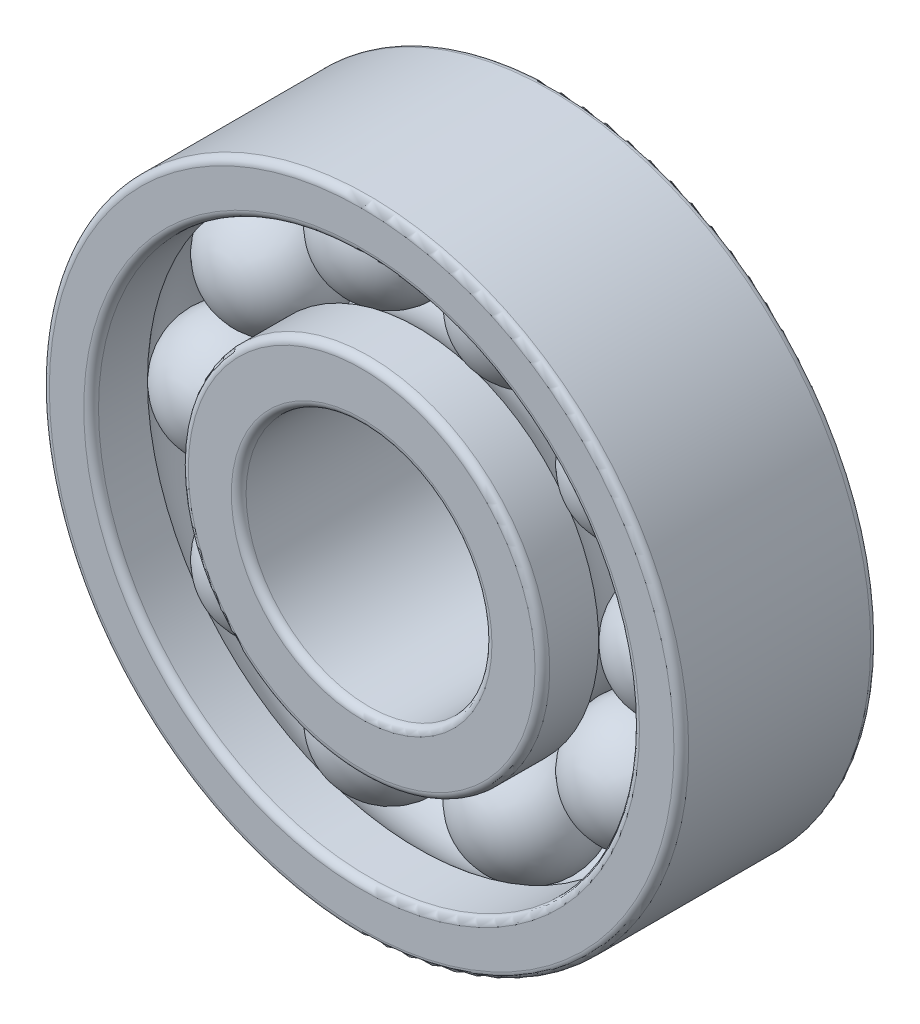
from build123d import *

# Parameters (mm, degrees)
SKETCH1_R             = 13
SKETCH1_R_2           = 11
BOSS_EXTRUDE1_DEPTH   = 8
SKETCH1_R_3           = 7.35
SKETCH1_R_4           = 5
BOSS_EXTRUDE1_2_DEPTH = 8
SKETCH4_R             = 2.5
CIRPATTERN1_COUNT     = 10
FILLET1_R             = 0.3
FILLET2_R             = 0.3


with BuildPart() as part:
    # Sketch1 → Boss-Extrude1 (new body)
    with BuildSketch(Plane.XY):
        Circle(SKETCH1_R)
        Circle(SKETCH1_R_2, mode=Mode.SUBTRACT)
    extrude(amount=BOSS_EXTRUDE1_DEPTH)


with BuildPart() as body_2:
    # Sketch1 → Boss-Extrude1 2 (new body)
    with BuildSketch(Plane.XY):
        Circle(SKETCH1_R_3)
        Circle(SKETCH1_R_4, mode=Mode.SUBTRACT)
    extrude(amount=BOSS_EXTRUDE1_2_DEPTH)


with BuildPart() as cut_sweep1_tool:
    # Cut-Sweep1: sweep along a path in Sketch2
    with BuildLine(Plane.XY.offset(4)) as cut_sweep1_path:
        CenterArc((0, 0), 9.175, 0, 360)
    # Sketch4 → Cut-Sweep1 (sweep)
    with BuildSketch(Plane(origin=(0, 0, 0), x_dir=(1, 0, 0), z_dir=(0, 1, 0))):
        with Locations((-9.175, -4)):
            Circle(SKETCH4_R)
    sweep(path=cut_sweep1_path.line)


with BuildPart() as part_1:
    add(part.part)

    # Cut-Sweep1: cut by cut_sweep1_tool
    add(cut_sweep1_tool.part, mode=Mode.SUBTRACT)

    # Fillet1
    fillet1_edges = [part_1.edges().sort_by_distance(p)[0] for p in [
        (-11, 0, 0),
        (-13, 0, 0),
        (-11, 0, 8),
        (-13, 0, 8),
    ]]
    fillet(fillet1_edges, radius=FILLET1_R)


with BuildPart() as body_2_1:
    add(body_2.part)

    # Cut-Sweep1: cut by cut_sweep1_tool
    add(cut_sweep1_tool.part, mode=Mode.SUBTRACT)

    # Fillet2
    fillet2_edges = [body_2_1.edges().sort_by_distance(p)[0] for p in [
        (-5, 0, 8),
        (-7.35, 0, 8),
        (-5, 0, 0),
        (-7.35, 0, 0),
    ]]
    fillet(fillet2_edges, radius=FILLET2_R)


with BuildPart() as body_3:
    # Sketch5 → Revolve1 (revolve)
    with BuildSketch(Plane(origin=(0, 0, 0), x_dir=(1, 0, 0), z_dir=(0, 1, 0))):
        with BuildLine():
            Line((-9.175, -1.5), (-9.175, -6.5))
            ThreePointArc((-9.175, -6.5), (-11.675, -4), (-9.175, -1.5))
        make_face()
    revolve(axis=Axis((-9.175, 0, 1.5), (0, 0, 1)))


with BuildPart() as cirpattern1_1:
    # CirPattern1: pattern copy
    add(body_3.part.rotate(Axis((0, 0, 8), (0, 0, -1)), 1 * 360 / CIRPATTERN1_COUNT))


with BuildPart() as cirpattern1_2:
    # CirPattern1: pattern copy
    add(body_3.part.rotate(Axis((0, 0, 8), (0, 0, -1)), 2 * 360 / CIRPATTERN1_COUNT))


with BuildPart() as cirpattern1_3:
    # CirPattern1: pattern copy
    add(body_3.part.rotate(Axis((0, 0, 8), (0, 0, -1)), 3 * 360 / CIRPATTERN1_COUNT))


with BuildPart() as cirpattern1_4:
    # CirPattern1: pattern copy
    add(body_3.part.rotate(Axis((0, 0, 8), (0, 0, -1)), 4 * 360 / CIRPATTERN1_COUNT))


with BuildPart() as cirpattern1_5:
    # CirPattern1: pattern copy
    add(body_3.part.rotate(Axis((0, 0, 8), (0, 0, -1)), 5 * 360 / CIRPATTERN1_COUNT))


with BuildPart() as cirpattern1_6:
    # CirPattern1: pattern copy
    add(body_3.part.rotate(Axis((0, 0, 8), (0, 0, -1)), 6 * 360 / CIRPATTERN1_COUNT))


with BuildPart() as cirpattern1_7:
    # CirPattern1: pattern copy
    add(body_3.part.rotate(Axis((0, 0, 8), (0, 0, -1)), 7 * 360 / CIRPATTERN1_COUNT))


with BuildPart() as cirpattern1_8:
    # CirPattern1: pattern copy
    add(body_3.part.rotate(Axis((0, 0, 8), (0, 0, -1)), 8 * 360 / CIRPATTERN1_COUNT))


with BuildPart() as cirpattern1_9:
    # CirPattern1: pattern copy
    add(body_3.part.rotate(Axis((0, 0, 8), (0, 0, -1)), 9 * 360 / CIRPATTERN1_COUNT))


solid = Compound([part_1.part, body_2_1.part, body_3.part, cirpattern1_1.part, cirpattern1_2.part, cirpattern1_3.part, cirpattern1_4.part, cirpattern1_5.part, cirpattern1_6.part, cirpattern1_7.part, cirpattern1_8.part, cirpattern1_9.part])
